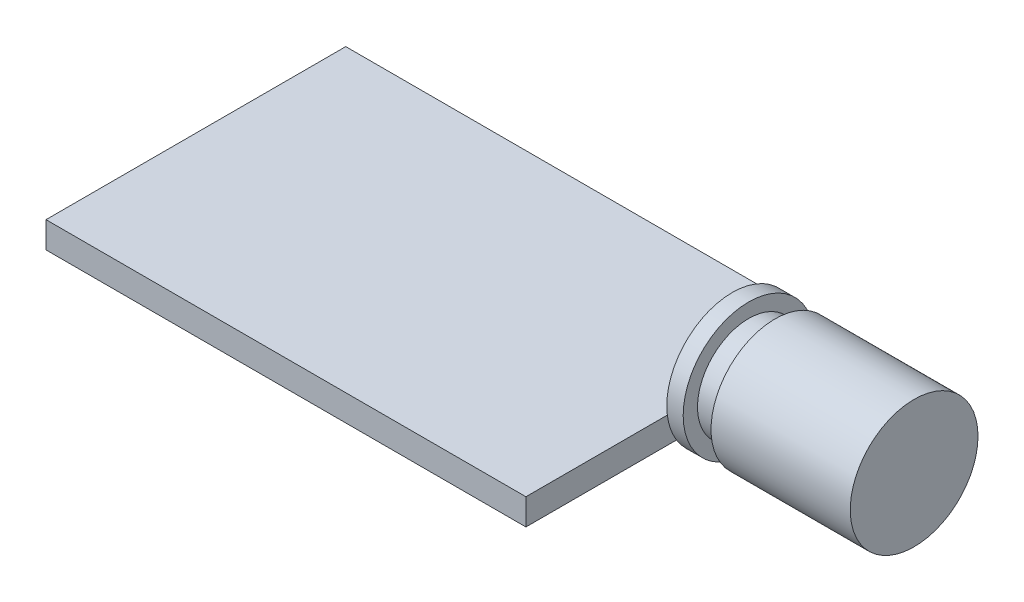
from build123d import *

# Parameters (mm, degrees)
SKETCH2_W           = 29.3
SKETCH2_H           = 18.3
BOSS_EXTRUDE1_DEPTH = 1.6
SKETCH3_R           = 4
BOSS_EXTRUDE2_DEPTH = 1
SKETCH4_R           = 3.125
BOSS_EXTRUDE3_DEPTH = 1.6
SKETCH5_R           = 3.9
BOSS_EXTRUDE4_DEPTH = 8.5


with BuildPart() as part:
    # Sketch2 → Boss-Extrude1 (new body)
    with BuildSketch(Plane(origin=(0, 0, 0), x_dir=(1, 0, 0), z_dir=(0, 1, 0))):
        with Locations((14.65, 9.15)):
            Rectangle(SKETCH2_W, SKETCH2_H)
    extrude(amount=BOSS_EXTRUDE1_DEPTH)

    # Sketch3 → Boss-Extrude2 (add)
    with BuildSketch(Plane(origin=(29.3, 0, 0), x_dir=(0, 0, -1), z_dir=(1, 0, 0))):
        with Locations((12.6, 2.1)):
            Circle(SKETCH3_R)
    extrude(amount=BOSS_EXTRUDE2_DEPTH)

    # Sketch4 → Boss-Extrude3 (add)
    with BuildSketch(Plane(origin=(30.3, 0, 0), x_dir=(0, 0, -1), z_dir=(1, 0, 0))):
        with Locations((12.6, 2.1)):
            Circle(SKETCH4_R)
    extrude(amount=BOSS_EXTRUDE3_DEPTH)

    # Sketch5 → Boss-Extrude4 (add)
    with BuildSketch(Plane(origin=(31.9, 0, 0), x_dir=(0, 0, -1), z_dir=(1, 0, 0))):
        with Locations((12.6, 2.1)):
            Circle(SKETCH5_R)
    extrude(amount=BOSS_EXTRUDE4_DEPTH)


solid = part.part
